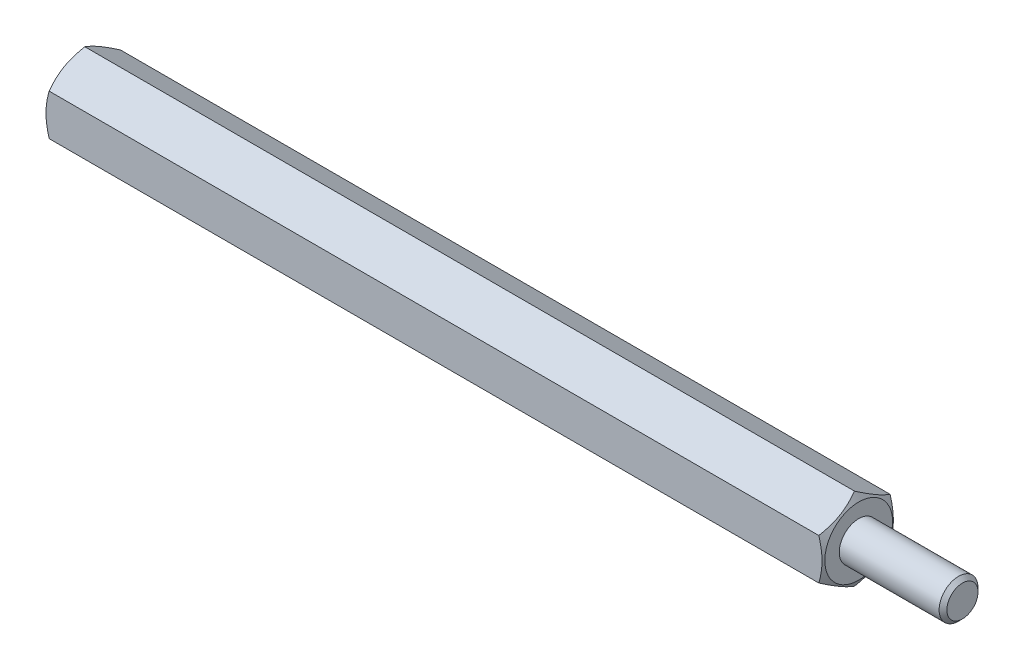
from build123d import *

# Parameters (mm, degrees)
BOSS_EXTRUDE1_DEPTH = 60
SKETCH2_R           = 1.5
BOSS_EXTRUDE2_DEPTH = 8
SKETCH3_R           = 1.5
CUT_EXTRUDE1_DEPTH  = 10
CHAMFER1_SIZE       = 0.3


with BuildPart() as part:
    # Sketch1 → Boss-Extrude1 (new body)
    with BuildSketch(Plane(origin=(0, 0, 0), x_dir=(0, 0, -1), z_dir=(1, 0, 0))):
        Polygon((0, 3.175426481), (-2.75, 1.58771324), (-2.75, -1.58771324), (0, -3.175426481), (2.75, -1.58771324), (2.75, 1.58771324), align=None)
    extrude(amount=BOSS_EXTRUDE1_DEPTH)

    # Sketch2 → Boss-Extrude2 (add)
    with BuildSketch(Plane(origin=(60, 0, 0), x_dir=(0, 0, -1), z_dir=(1, 0, 0))):
        Circle(SKETCH2_R)
    extrude(amount=BOSS_EXTRUDE2_DEPTH)

    # Sketch3 → Cut-Extrude1 (cut)
    with BuildSketch(Plane.ZY):
        Circle(SKETCH3_R)
    extrude(amount=-CUT_EXTRUDE1_DEPTH, mode=Mode.SUBTRACT)

    # Sketch4 → Cut-Revolve1 (revolve, cut)
    with BuildSketch(Plane(origin=(0, 0, 0), x_dir=(1, 0, 0), z_dir=(0, 1, 0))):
        Polygon((0, 10.219809024), (4.392081913, 10.219809024), (0, 2.6125), align=None)
        Polygon((60, 2.6125), (60, 10.219809024), (55.607918087, 10.219809024), align=None)
    revolve(axis=Axis((0, 0, 0), (-1, 0, 0)), mode=Mode.SUBTRACT)

    # Chamfer1
    chamfer1_edges = [part.edges().sort_by_distance(p)[0] for p in [
        (68, 0, 1.5),
    ]]
    chamfer(chamfer1_edges, length=CHAMFER1_SIZE)


solid = part.part
